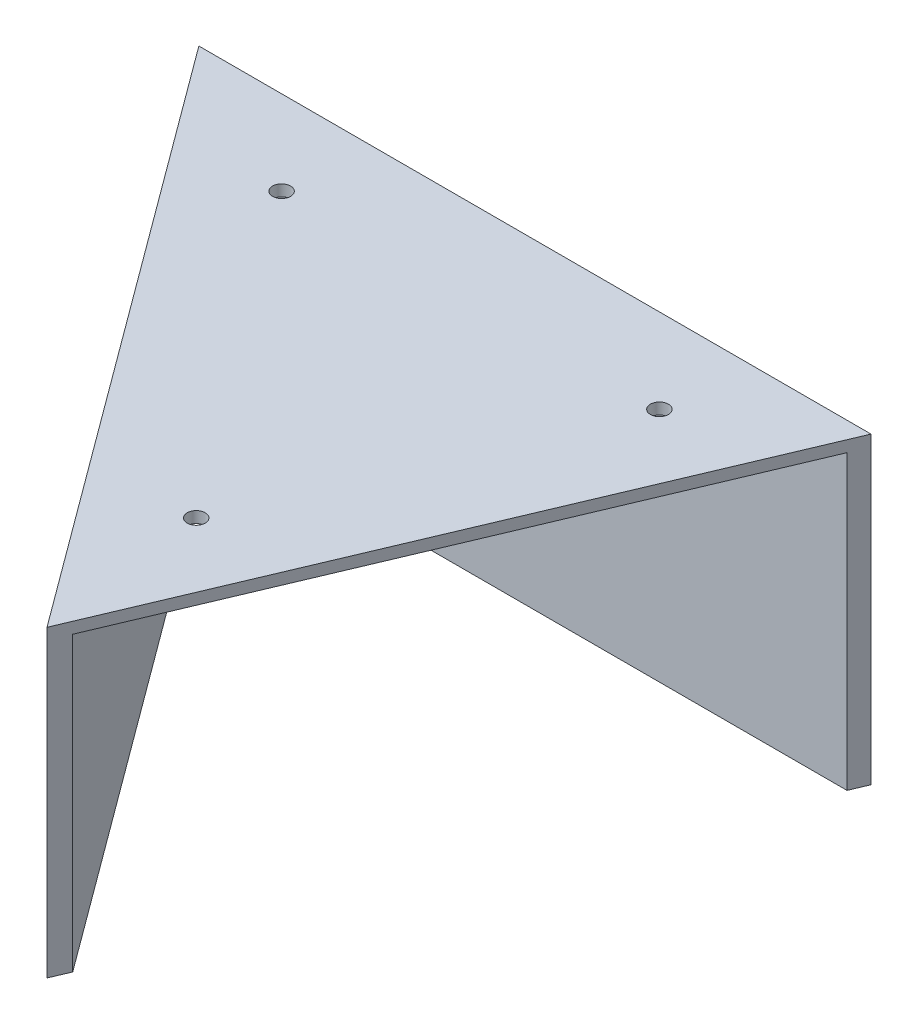
from build123d import *

# Parameters (mm, degrees)
BOSS_EXTRUDE1_DEPTH = 2
BOSS_EXTRUDE2_DEPTH = 52
SKETCH4_R           = 1.6
CUT_EXTRUDE3_DEPTH  = 52
CUT_EXTRUDE4_DEPTH  = 52


with BuildPart() as part:
    # Sketch1 → Boss-Extrude1 (new body)
    with BuildSketch(Plane(origin=(0, 0, 0), x_dir=(1, 0, 0), z_dir=(0, 1, 0))):
        Polygon((0, 0), (-69.5, 0), (6.5, 103), (50, 0), (40, 0), align=None)
    extrude(amount=BOSS_EXTRUDE1_DEPTH)

    # Sketch2 → Boss-Extrude2 (add)
    with BuildSketch(Plane.XZ):
        Polygon((50, 0), (-69.5, 0), (6.5, -103), align=None)
        Polygon((5.786026753, -96.979592592), (45.476437216, -3), (-63.558138655, -3), align=None, mode=Mode.SUBTRACT)
    extrude(amount=BOSS_EXTRUDE2_DEPTH)

    # Sketch4 → Cut-Extrude3 (cut)
    with BuildSketch(Plane.XZ):
        with Locations((-39.790693273, -15)):
            Circle(SKETCH4_R)
        with Locations((27.382186082, -15)):
            Circle(SKETCH4_R)
        with Locations((2.930133764, -72.897962959)):
            Circle(SKETCH4_R)
    extrude(amount=-CUT_EXTRUDE3_DEPTH, mode=Mode.SUBTRACT)

    # Sketch6 → Cut-Extrude4 (cut)
    with BuildSketch(Plane.XZ.offset(52)):
        Polygon((5.786026753, -96.979592592), (13.566318251, -107.523935016), (48.733009709, -3), (45.476437216, -3), align=None)
    extrude(amount=-CUT_EXTRUDE4_DEPTH, mode=Mode.SUBTRACT)


with BuildPart() as body_2:
    # Mirror1: mirrored copy
    add(part.part.mirror(Plane(origin=(0, 2, 0), x_dir=(1, 0, 0), z_dir=(0, 0, -1))))


solid = body_2.part
